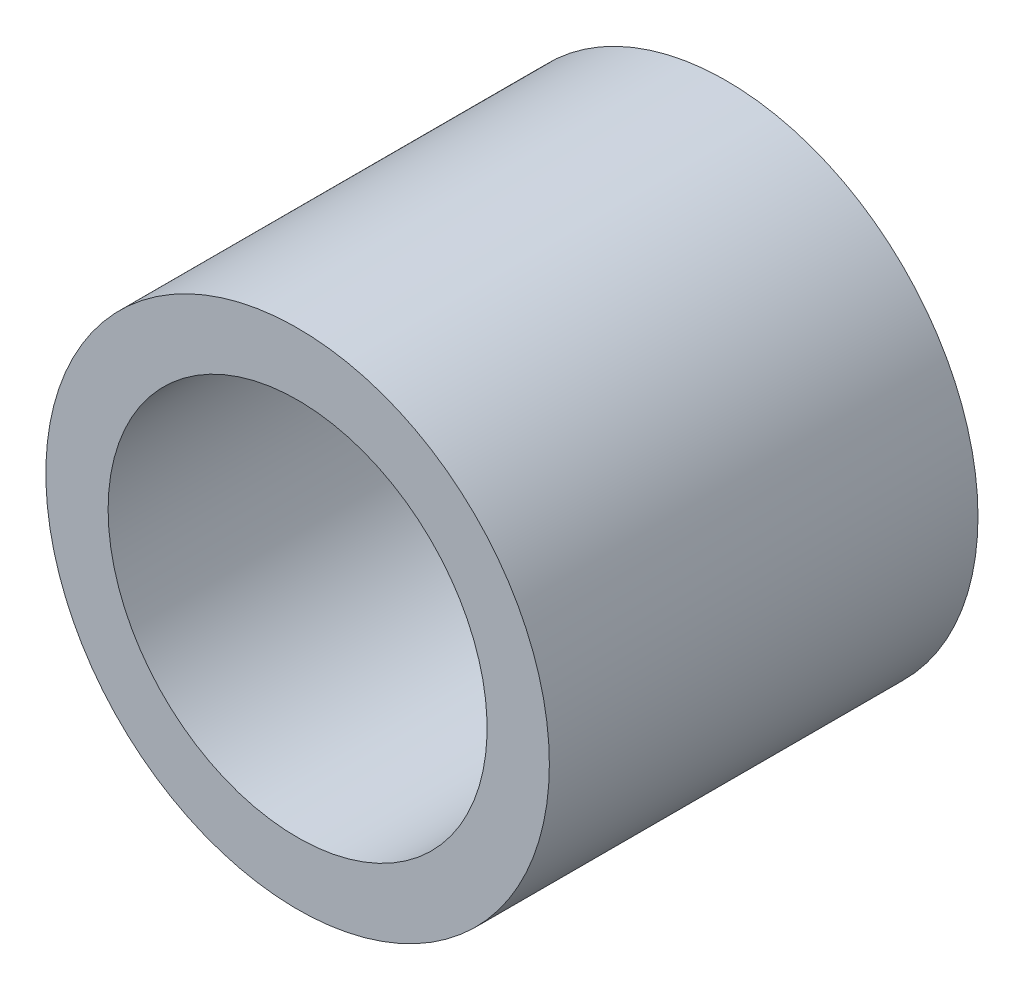
from build123d import *

# Parameters (mm, degrees)
CROQUIS2_R              = 27.9
SALIENTE_EXTRUIR1_DEPTH = 47.5
CROQUIS3_R              = 21
CORTAR_EXTRUIR1_DEPTH   = 47.5


with BuildPart() as part:
    # Croquis2 → Saliente-Extruir1 (new body)
    with BuildSketch(Plane.XY):
        Circle(CROQUIS2_R)
    extrude(amount=SALIENTE_EXTRUIR1_DEPTH)

    # Croquis3 → Cortar-Extruir1 (cut)
    with BuildSketch(Plane(origin=(0, 0, 0), x_dir=(-1, 0, 0), z_dir=(0, 0, -1))):
        Circle(CROQUIS3_R)
    extrude(amount=-CORTAR_EXTRUIR1_DEPTH, mode=Mode.SUBTRACT)


solid = part.part
